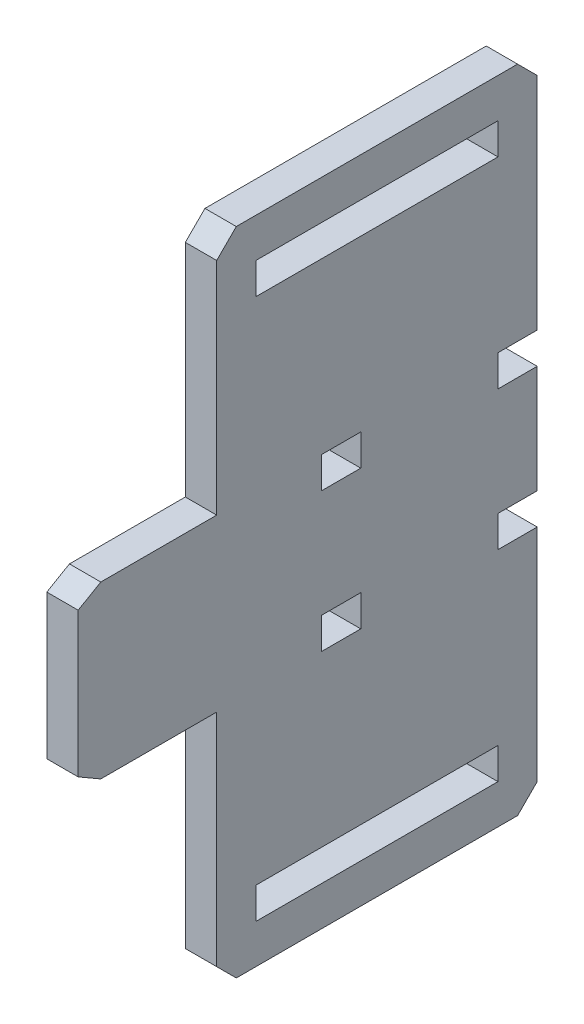
from build123d import *

# Parameters (mm, degrees)
SKETCH1_W           = 47.051856626
SKETCH1_H           = 6.096
SKETCH1_W_2         = 7.62
BOSS_EXTRUDE1_DEPTH = 3.048
CHAMFER2_SIZE       = 3.81


with BuildPart() as part:
    # Sketch1 → Boss-Extrude1 (new, symmetric)
    with BuildSketch(Plane(origin=(0, 0, 0), x_dir=(0, 0, -1), z_dir=(1, 0, 0))):
        Polygon((45.72, -63.246), (45.72, -16.5735), (38.1, -16.5735), (38.1, -10.4775), (45.72, -10.4775), (45.72, 10.4775), (38.1, 10.4775), (38.1, 16.5735), (45.72, 16.5735), (45.72, 63.246), (-16.571856626, 63.246), (-16.571856626, 16.5735), (-39.096447575, 16.5735), (-43.495856626, 14.0335), (-43.495856626, -14.0335), (-39.096447575, -16.5735), (-16.571856626, -16.5735), (-16.571856626, -63.246), align=None)
        with Locations((14.574071687, -52.578)):
            Rectangle(SKETCH1_W, SKETCH1_H, mode=Mode.SUBTRACT)
        with Locations((14.574071687, 52.578)):
            Rectangle(SKETCH1_W, SKETCH1_H, mode=Mode.SUBTRACT)
        with Locations((7.62, 13.5255)):
            Rectangle(SKETCH1_W_2, SKETCH1_H, mode=Mode.SUBTRACT)
        with Locations((7.62, -13.5255)):
            Rectangle(SKETCH1_W_2, SKETCH1_H, mode=Mode.SUBTRACT)
    extrude(amount=BOSS_EXTRUDE1_DEPTH, both=True)

    # Chamfer2
    chamfer2_edges = [part.edges().sort_by_distance(p)[0] for p in [
        (0, -63.246, -45.72),
        (0, -63.246, 16.571856626),
        (0, 63.246, -45.72),
        (0, 63.246, 16.571856626),
    ]]
    chamfer(chamfer2_edges, length=CHAMFER2_SIZE)


solid = part.part
